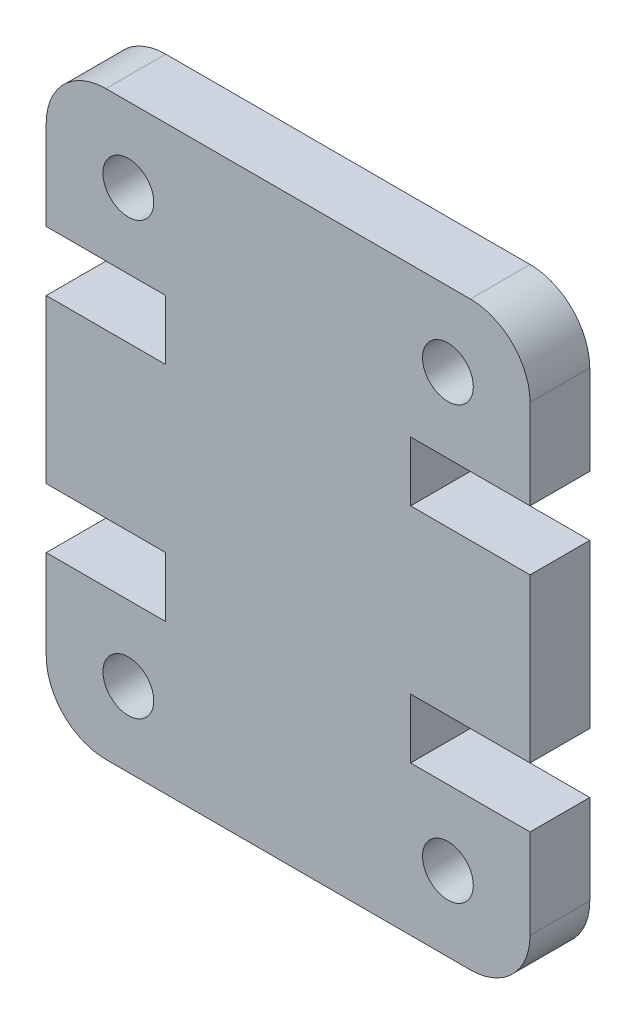
from build123d import *

# Parameters (mm, degrees)
SKETCH2_R           = 0.85
BOSS_EXTRUDE1_DEPTH = 4
SKETCH3_W           = 16.2
SKETCH3_H           = 19.455
CUT_EXTRUDE1_DEPTH  = 2


with BuildPart() as part:
    # Sketch2 → Boss-Extrude1 (new body)
    with BuildSketch(Plane.XY):
        with BuildLine():
            Line((0, 7), (0, 12.455))
            Line((0, 12.455), (4, 12.455))
            Line((4, 12.455), (4, 14.455))
            Line((4, 14.455), (0, 14.455))
            Line((0, 14.455), (0, 17.455))
            ThreePointArc((0, 17.455), (0.585786438, 18.869213562), (2, 19.455))
            Line((2, 19.455), (14.2, 19.455))
            ThreePointArc((14.2, 19.455), (15.614213562, 18.869213562), (16.2, 17.455))
            Line((16.2, 17.455), (16.2, 14.455))
            Line((16.2, 14.455), (12.2, 14.455))
            Line((12.2, 14.455), (12.2, 12.455))
            Line((12.2, 12.455), (16.2, 12.455))
            Line((16.2, 12.455), (16.2, 7))
            Line((16.2, 7), (12.2, 7))
            Line((12.2, 7), (12.2, 5))
            Line((12.2, 5), (16.2, 5))
            Line((16.2, 5), (16.2, 2))
            ThreePointArc((16.2, 2), (15.614213562, 0.585786438), (14.2, 0))
            Line((14.2, 0), (2, 0))
            ThreePointArc((2, 0), (0.585786438, 0.585786438), (0, 2))
            Line((0, 2), (0, 5))
            Line((0, 5), (4, 5))
            Line((4, 5), (4, 7))
            Line((4, 7), (0, 7))
        make_face()
        with Locations((13.45, 2.5)):
            Circle(SKETCH2_R, mode=Mode.SUBTRACT)
        with Locations((2.75, 16.955)):
            Circle(SKETCH2_R, mode=Mode.SUBTRACT)
        with Locations((2.75, 2.5)):
            Circle(SKETCH2_R, mode=Mode.SUBTRACT)
        with Locations((13.45, 16.955)):
            Circle(SKETCH2_R, mode=Mode.SUBTRACT)
    extrude(amount=BOSS_EXTRUDE1_DEPTH)

    # Sketch3 → Cut-Extrude1 (cut)
    with BuildSketch(Plane.XY.offset(4)):
        with Locations((8.1, 9.7275)):
            Rectangle(SKETCH3_W, SKETCH3_H)
    extrude(amount=-CUT_EXTRUDE1_DEPTH, mode=Mode.SUBTRACT)


solid = part.part
